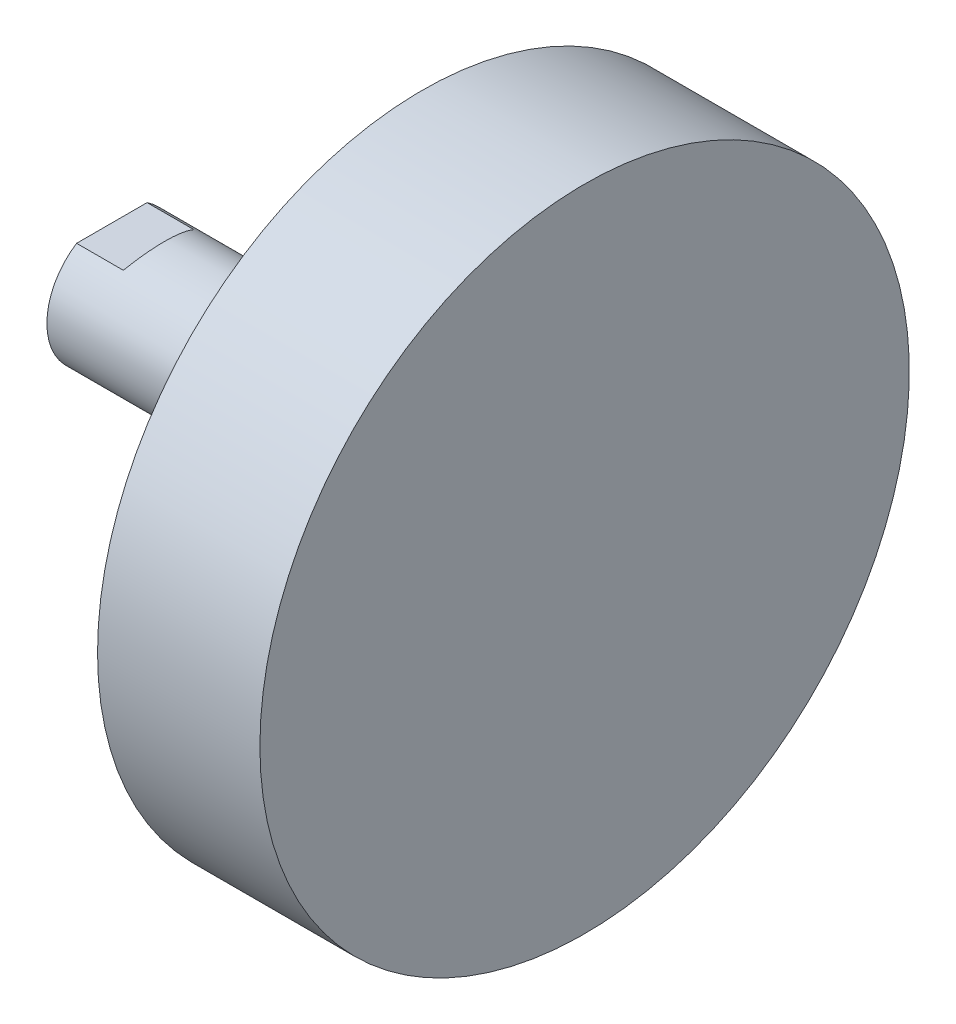
from build123d import *

# Parameters (mm, degrees)
SKETCH1_W               = 91
SKETCH1_H               = 12.5
SKETCH2_W               = 31.25
SKETCH2_H               = 62.5
CUT_EXTRUDE1_DEPTH      = 25
CUT_EXTRUDE1_DEPTH_BACK = 25


with BuildPart() as part:
    # Sketch1 → Revolve1 (revolve)
    with BuildSketch(Plane.XY):
        with Locations((34.5, 6.25)):
            Rectangle(SKETCH1_W, SKETCH1_H)
    revolve(axis=Axis((80, 0, 0), (-1, 0, 0)))

    # Sketch2 → Revolve2 (revolve)
    with BuildSketch(Plane.XY):
        with Locations((64.375, 31.25)):
            Rectangle(SKETCH2_W, SKETCH2_H)
    revolve(axis=Axis((80, 0, 0), (-1, 0, 0)))

    # Sketch3 → Cut-Extrude1 (cut, two sides: drawn at the far end of the back side and taken through both)
    with BuildSketch(Plane.XY.offset(-CUT_EXTRUDE1_DEPTH_BACK)):
        Polygon((-67, -28), (8.103629711, -28), (-2, -10.5), (-11, -10.5), (-11, -15.5), (-56, -15.5), (-56, 15.5), (-11, 15.5), (-11, 10.5), (-2, 10.5), (8.103629711, 28), (-67, 28), align=None)
    extrude(amount=CUT_EXTRUDE1_DEPTH + CUT_EXTRUDE1_DEPTH_BACK, mode=Mode.SUBTRACT)

    # Sketch4 → Cut-Revolve1 (revolve, cut)
    with BuildSketch(Plane.XY):
        Polygon((-11, 0), (-11, 9.5), (-10, 8.5), (-4, 8.5), (-4, 8), (-2.9175, 6.9175), (20.5, 6.9175), (24.493820487, 0), align=None)
    revolve(axis=Axis((24.493820487, 0, 0), (-1, 0, 0)), mode=Mode.SUBTRACT)


solid = part.part
